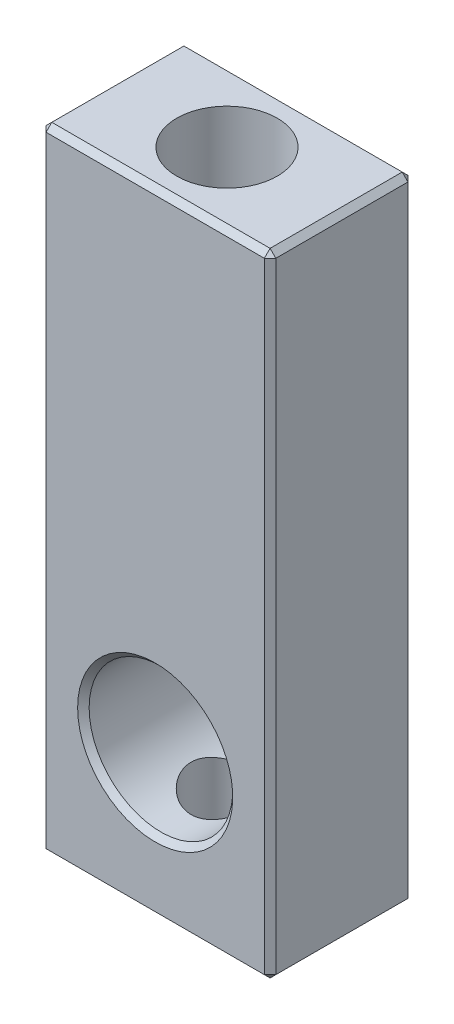
from build123d import *

# Parameters (mm, degrees)
SKIZZE1_W                       = 8
SKIZZE1_H                       = 22
SKIZZE1_R                       = 2.5
AUFSATZ_LINEAR_AUSTRAGEN1_DEPTH = 5
M3_GEWINDEBOHRUNG1_REACH        = 24.913
M3_GEWINDEBOHRUNG1_BORE_R       = 1.25
FASE1_SIZE                      = 0.2
FASE2_SIZE                      = 0.2
SKIZZE4_R                       = 1.75
SCHNITT_LINEAR_AUSTRAGEN1_DEPTH = 13.727922148
M3_GEWINDEBOHRUNG2_D            = 2.5


with BuildPart() as part:
    # Skizze1 → Aufsatz-Linear austragen1 (new body)
    with BuildSketch(Plane.XY):
        with Locations((0, 6)):
            Rectangle(SKIZZE1_W, SKIZZE1_H)
        Circle(SKIZZE1_R, mode=Mode.SUBTRACT)
    extrude(amount=AUFSATZ_LINEAR_AUSTRAGEN1_DEPTH)

    # M3 Gewindebohrung1 bore → M3 Gewindebohrung1 (cut, up to next)
    with BuildSketch(Plane(origin=(0, -5, 0), x_dir=(-1, 0, 0), z_dir=(0, -1, 0)), mode=Mode.PRIVATE) as m3_gewindebohrung1_sk1:
        with Locations((0, -2.5)):
            Circle(M3_GEWINDEBOHRUNG1_BORE_R)
    m3_gewindebohrung1_tool1 = extrude(m3_gewindebohrung1_sk1.sketch, amount=-M3_GEWINDEBOHRUNG1_REACH, mode=Mode.PRIVATE) & part.part
    add(m3_gewindebohrung1_tool1.solids().sort_by_distance((0, -5, 2.5))[0], mode=Mode.SUBTRACT)

    # Fase1
    fase1_edges = [part.edges().sort_by_distance(p)[0] for p in [
        (-2.5, 0, 0),
        (-2.5, 0, 5),
    ]]
    chamfer(fase1_edges, length=FASE1_SIZE)

    # Fase2
    fase2_edges = [part.edges().sort_by_distance(p)[0] for p in [
        (4, 6, 5),
        (0, 17, 5),
        (-4, 6, 5),
        (0, 17, 0),
        (4, 6, 0),
        (0, -5, 0),
        (-4, 6, 0),
        (0, -5, 5),
        (-4, 17, 2.5),
        (4, 17, 2.5),
        (4, -5, 2.5),
        (-4, -5, 2.5),
    ]]
    chamfer(fase2_edges, length=FASE2_SIZE)

    # Skizze4 → Schnitt-Linear austragen1 (cut, through all)
    with BuildSketch(Plane(origin=(0, 6, 0), x_dir=(1, 0, 0), z_dir=(0, 1, 0))):
        with Locations(Location((0, -2.5, 0), (0, 0, 270))):
            Circle(SKIZZE4_R)
    extrude(amount=SCHNITT_LINEAR_AUSTRAGEN1_DEPTH, mode=Mode.SUBTRACT)

    # M3 Gewindebohrung2 (through all)
    with Locations(Plane(origin=(0, 6, 0), x_dir=(1, 0, 0), z_dir=(0, 1, 0))):
        with Locations((0, -2.5)):
            Hole(M3_GEWINDEBOHRUNG2_D / 2)


solid = part.part
